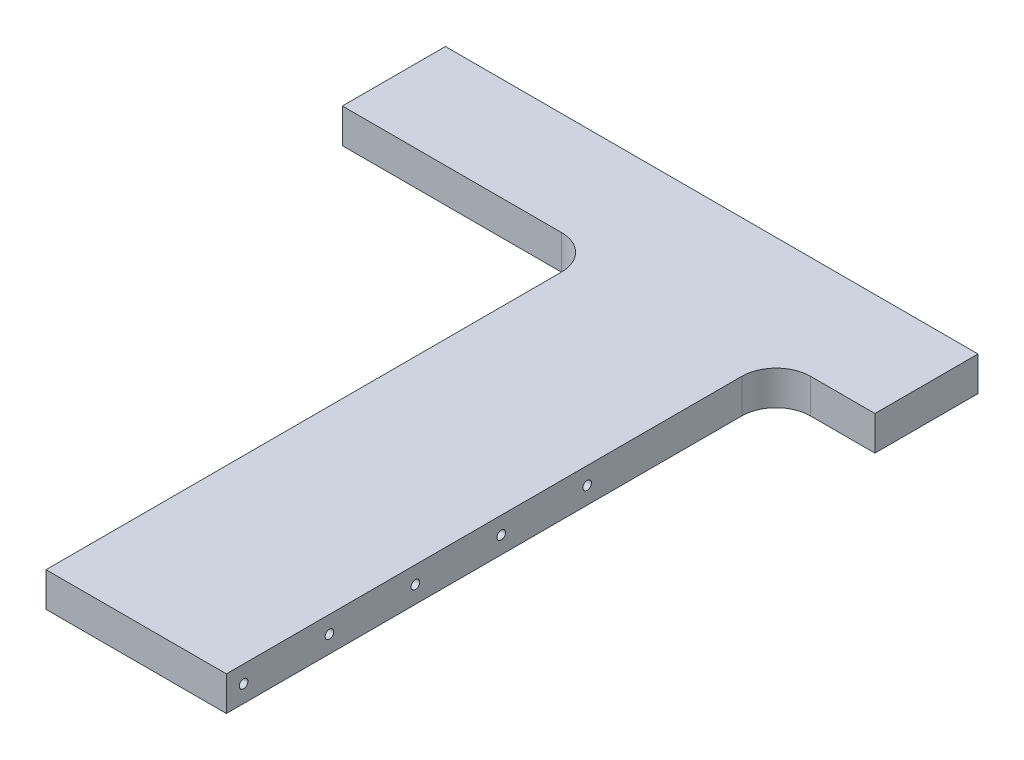
from build123d import *

# Parameters (mm, degrees)
AUFSATZ_LINEAR_AUSTRAGEN1_DEPTH       = 20
M6_GEWINDEBOHRUNG1_AT_2_COUNT         = 2
M6_GEWINDEBOHRUNG1_AT_2_PITCH         = 50
M6_GEWINDEBOHRUNG1_AT_3_COUNT         = 2
M6_GEWINDEBOHRUNG1_AT_3_PITCH         = 100
M6_GEWINDEBOHRUNG1_AT_4_COUNT         = 2
M6_GEWINDEBOHRUNG1_AT_4_PITCH         = 150
M6_GEWINDEBOHRUNG1_AT_5_COUNT         = 2
M6_GEWINDEBOHRUNG1_AT_5_PITCH         = 206.155281281
M6_GEWINDEBOHRUNG1_AT_6_COUNT         = 2
M6_GEWINDEBOHRUNG1_AT_6_PITCH         = 200
M6_GEWINDEBOHRUNG2_D                  = 5
M6_GEWINDEBOHRUNG2_DEPTH              = 17
M6_GEWINDEBOHRUNG2_TIP                = 1.502151548
VERRUNDUNG1_R                         = 20
F_6_0MM_TRANSITIONAL_STIFTLOCH1_D     = 6
F_6_0MM_TRANSITIONAL_STIFTLOCH1_DEPTH = 17
F_6_0MM_TRANSITIONAL_STIFTLOCH1_TIP   = 1.802581857


with BuildPart() as part:
    # Skizze1 → Aufsatz-Linear austragen1 (new body)
    with BuildSketch(Plane(origin=(0, 0, 0), x_dir=(1, 0, 0), z_dir=(0, 1, 0))):
        Polygon((-52.5, 0), (52.5, 0), (52.5, 320), (110, 320), (110, 380), (-200, 380), (-200, 320), (-52.5, 320), align=None)
    extrude(amount=AUFSATZ_LINEAR_AUSTRAGEN1_DEPTH)

    # Skizze4 → M6 Gewindebohrung1 (revolve, cut)
    with BuildSketch(Plane(origin=(52.5, 10, -10), x_dir=(0, 0, -1), z_dir=(0, 1, 0))):
        Polygon((0, 0), (0, 18.502151548), (2.5, 17), (2.5, 0), align=None)
    m6_gewindebohrung1 = revolve(axis=Axis((58.85, 10, -10), (-1, 0, 0)), mode=Mode.SUBTRACT)

    # M6 Gewindebohrung1 at 2: M6 Gewindebohrung1 ×2
    with Locations(*[(0, 0, -i * M6_GEWINDEBOHRUNG1_AT_2_PITCH) for i in range(1, M6_GEWINDEBOHRUNG1_AT_2_COUNT)]):
        add(m6_gewindebohrung1, mode=Mode.SUBTRACT)

    # M6 Gewindebohrung1 at 3: M6 Gewindebohrung1 ×2
    with Locations(*[(0, 0, -i * M6_GEWINDEBOHRUNG1_AT_3_PITCH) for i in range(1, M6_GEWINDEBOHRUNG1_AT_3_COUNT)]):
        add(m6_gewindebohrung1, mode=Mode.SUBTRACT)

    # M6 Gewindebohrung1 at 4: M6 Gewindebohrung1 ×2
    with Locations(*[(0, 0, -i * M6_GEWINDEBOHRUNG1_AT_4_PITCH) for i in range(1, M6_GEWINDEBOHRUNG1_AT_4_COUNT)]):
        add(m6_gewindebohrung1, mode=Mode.SUBTRACT)

    # M6 Gewindebohrung1 at 5: M6 Gewindebohrung1 ×2
    with Locations(*[Vector(0, 0.242535625, -0.9701425) * (i * M6_GEWINDEBOHRUNG1_AT_5_PITCH) for i in range(1, M6_GEWINDEBOHRUNG1_AT_5_COUNT)]):
        add(m6_gewindebohrung1, mode=Mode.SUBTRACT)

    # M6 Gewindebohrung1 at 6: M6 Gewindebohrung1 ×2
    with Locations(*[(0, 0, -i * M6_GEWINDEBOHRUNG1_AT_6_PITCH) for i in range(1, M6_GEWINDEBOHRUNG1_AT_6_COUNT)]):
        add(m6_gewindebohrung1, mode=Mode.SUBTRACT)

    # Spiegeln1: M6 Gewindebohrung1 across plane
    add(m6_gewindebohrung1.mirror(Plane(origin=(0, 0, 0), x_dir=(0, 0, 1), z_dir=(1, 0, 0))), mode=Mode.SUBTRACT)

    # Spiegeln1 copy 1 sketch → Spiegeln1 copy 1 (revolve, cut)
    with BuildSketch(Plane(origin=(-52.5, 10, -60), x_dir=(0, 0, -1), z_dir=(0, 1, 0))):
        Polygon((0, 0), (0, -18.502151548), (2.5, -17), (2.5, 0), align=None)
    revolve(axis=Axis((-58.85, 10, -60), (-1, 0, 0)), mode=Mode.SUBTRACT)

    # Spiegeln1 copy 2 sketch → Spiegeln1 copy 2 (revolve, cut)
    with BuildSketch(Plane(origin=(-52.5, 10, -110), x_dir=(0, 0, -1), z_dir=(0, 1, 0))):
        Polygon((0, 0), (0, -18.502151548), (2.5, -17), (2.5, 0), align=None)
    revolve(axis=Axis((-58.85, 10, -110), (-1, 0, 0)), mode=Mode.SUBTRACT)

    # Spiegeln1 copy 3 sketch → Spiegeln1 copy 3 (revolve, cut)
    with BuildSketch(Plane(origin=(-52.5, 10, -160), x_dir=(0, 0, -1), z_dir=(0, 1, 0))):
        Polygon((0, 0), (0, -18.502151548), (2.5, -17), (2.5, 0), align=None)
    revolve(axis=Axis((-58.85, 10, -160), (-1, 0, 0)), mode=Mode.SUBTRACT)

    # Spiegeln1 copy 4 sketch → Spiegeln1 copy 4 (revolve, cut)
    with BuildSketch(Plane(origin=(-52.5, 60, -210), x_dir=(0, 0, -1), z_dir=(0, 1, 0))):
        Polygon((0, 0), (0, -18.502151548), (2.5, -17), (2.5, 0), align=None)
    revolve(axis=Axis((-58.85, 60, -210), (-1, 0, 0)), mode=Mode.SUBTRACT)

    # Spiegeln1 copy 5 sketch → Spiegeln1 copy 5 (revolve, cut)
    with BuildSketch(Plane(origin=(-52.5, 10, -210), x_dir=(0, 0, -1), z_dir=(0, 1, 0))):
        Polygon((0, 0), (0, -18.502151548), (2.5, -17), (2.5, 0), align=None)
    revolve(axis=Axis((-58.85, 10, -210), (-1, 0, 0)), mode=Mode.SUBTRACT)

    # M6 Gewindebohrung2
    with Locations(Plane(origin=(0, 0, -380), x_dir=(-1, 0, 0), z_dir=(0, 0, -1))):
        with Locations((-90, 10), (180, 10), (0, 10)):
            Hole(M6_GEWINDEBOHRUNG2_D / 2, depth=M6_GEWINDEBOHRUNG2_DEPTH)
            with Locations((0, 0, -(M6_GEWINDEBOHRUNG2_DEPTH + M6_GEWINDEBOHRUNG2_TIP / 2))):  # 118° drill point
                Cone(0, M6_GEWINDEBOHRUNG2_D / 2, M6_GEWINDEBOHRUNG2_TIP, mode=Mode.SUBTRACT)

    # Verrundung1
    verrundung1_edges = [part.edges().sort_by_distance(p)[0] for p in [
        (-52.5, 10, -320),
        (52.5, 10, -320),
    ]]
    fillet(verrundung1_edges, radius=VERRUNDUNG1_R)

    # Ø6.0mm Transitional Stiftloch1
    with Locations(Plane(origin=(0, 0, -380), x_dir=(-1, 0, 0), z_dir=(0, 0, -1))):
        with Locations((120, 10), (-30, 10)):
            Hole(F_6_0MM_TRANSITIONAL_STIFTLOCH1_D / 2, depth=F_6_0MM_TRANSITIONAL_STIFTLOCH1_DEPTH)
            with Locations((0, 0, -(F_6_0MM_TRANSITIONAL_STIFTLOCH1_DEPTH + F_6_0MM_TRANSITIONAL_STIFTLOCH1_TIP / 2))):  # 118° drill point
                Cone(0, F_6_0MM_TRANSITIONAL_STIFTLOCH1_D / 2, F_6_0MM_TRANSITIONAL_STIFTLOCH1_TIP, mode=Mode.SUBTRACT)


solid = part.part
